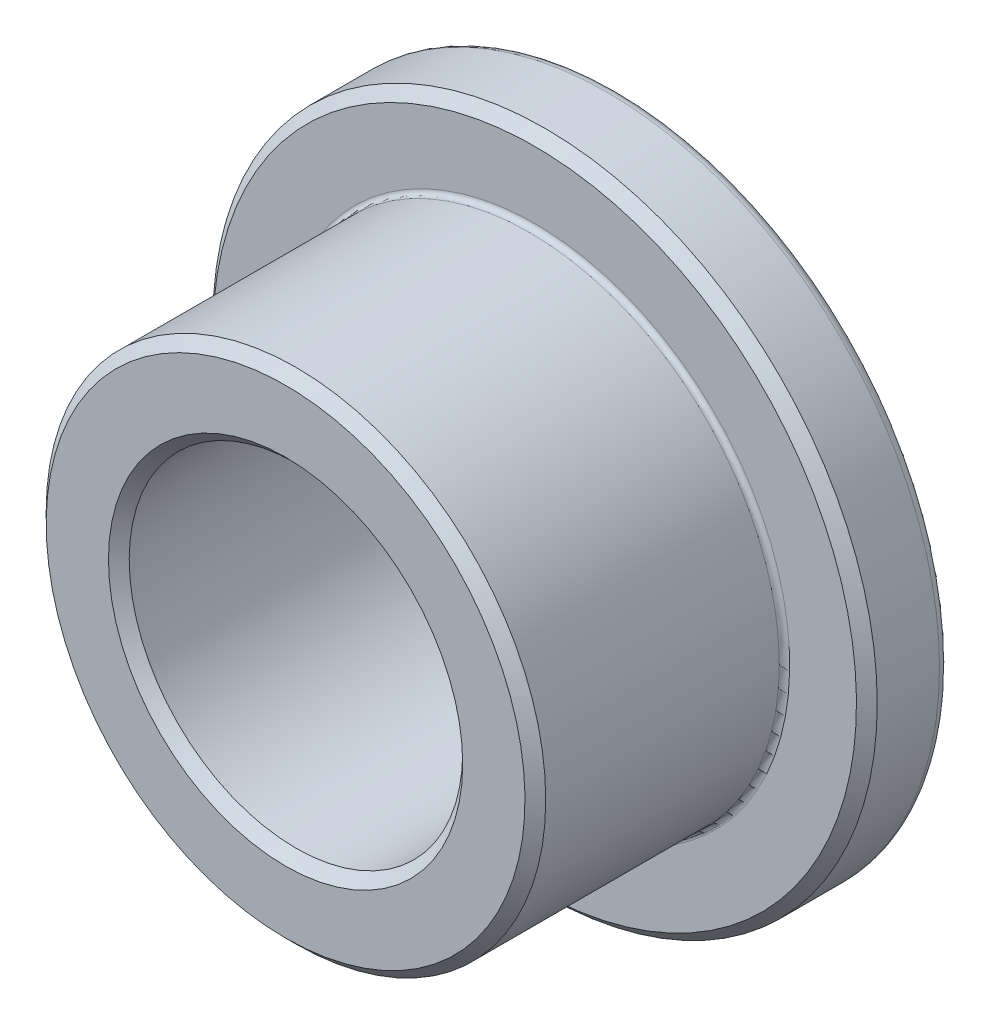
from build123d import *

# Parameters (mm, degrees)
CHAMFER1_SIZE = 0.1984375
FILLET1_R     = 0.1984375
FILLET2_R     = 0.09921875


with BuildPart() as part:
    # Sketch3 → Revolve1 (revolve)
    with BuildSketch(Plane(origin=(0, 0, 0), x_dir=(0, 0, -1), z_dir=(1, 0, 0))):
        Polygon((3.175, 6.35), (1.5875, 6.35), (1.5875, 4.7752), (-3.175, 4.7752), (-3.175, 3.1877), (3.175, 3.1877), align=None)
    revolve(axis=Axis((0, 0, -3.175), (0, 0, 1)))

    # Chamfer1
    chamfer1_edges = [part.edges().sort_by_distance(p)[0] for p in [
        (0, -3.1877, 3.175),
        (0, -4.7752, 3.175),
        (0, -6.35, -1.5875),
    ]]
    chamfer(chamfer1_edges, length=CHAMFER1_SIZE)

    # Fillet1
    fillet1_edges = [part.edges().sort_by_distance(p)[0] for p in [
        (0, -6.35, -3.175),
    ]]
    fillet(fillet1_edges, radius=FILLET1_R)

    # Fillet2
    fillet2_edges = [part.edges().sort_by_distance(p)[0] for p in [
        (0, -4.7752, -1.5875),
    ]]
    fillet(fillet2_edges, radius=FILLET2_R)


solid = part.part
